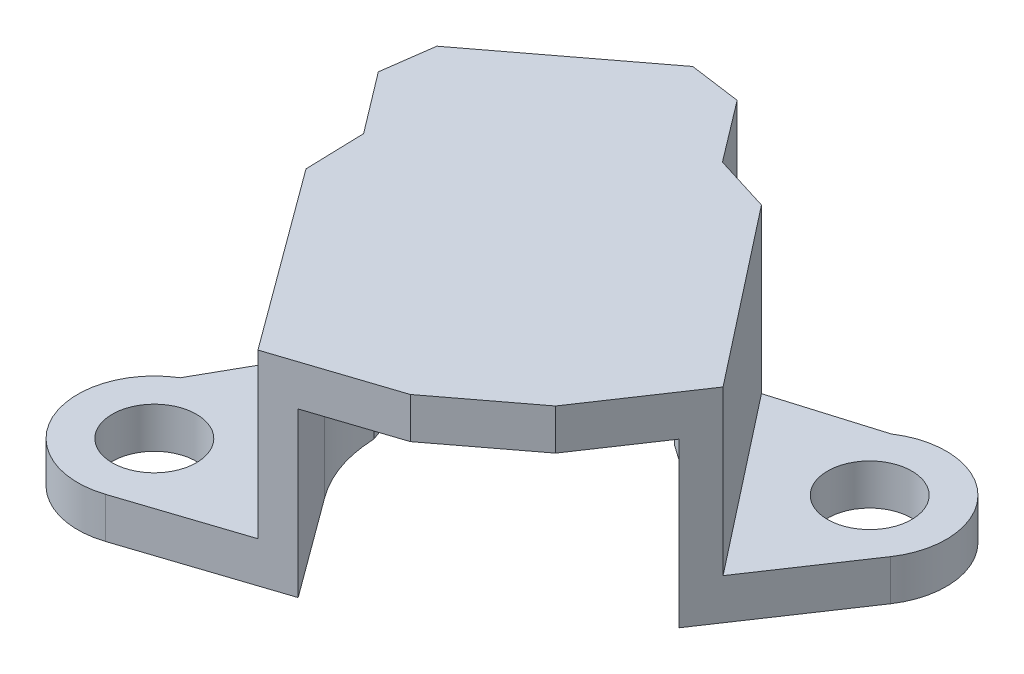
from build123d import *

# Parameters (mm, degrees)
SKETCH1_R             = 2.6162
BOSS_EXTRUDE1_DEPTH   = 2.54
BOSS_EXTRUDE1_2_DEPTH = 2.54
BOSS_EXTRUDE2_DEPTH   = 12.7
BOSS_EXTRUDE3_DEPTH   = 12.7
CUT_EXTRUDE1_DEPTH    = 10.16
BOSS_EXTRUDE5_DEPTH   = 12.7
CUT_EXTRUDE2_DEPTH    = 10.16


with BuildPart() as part:
    # Sketch1 → Boss-Extrude1 (new body)
    with BuildSketch(Plane(origin=(0, 0, 0), x_dir=(1, 0, 0), z_dir=(0, 1, 0))):
        with BuildLine():
            Line((-10.149829081, -0.78559745), (-12.970179614, -5.786096043))
            ThreePointArc((-12.970179614, -5.786096043), (-14.833663899, -11.850889023), (-9.017306722, -14.385504725))
            Line((-9.017306722, -14.385504725), (-1.886569513, -12.038188494))
            Line((-1.886569513, -12.038188494), (-10.149829081, -0.78559745))
        make_face()
        with Locations((-10.506432822, -9.861799418)):
            Circle(SKETCH1_R, mode=Mode.SUBTRACT)
    extrude(amount=BOSS_EXTRUDE1_DEPTH)



with BuildPart() as body_2:
    # Sketch1 → Boss-Extrude1 2 (new body)
    with BuildSketch(Plane(origin=(0, 0, 0), x_dir=(1, 0, 0), z_dir=(0, 1, 0))):
        with BuildLine():
            Line((5.95620443, 11.428082994), (14.562195858, 0.435395631))
            Line((14.562195858, 0.435395631), (18.746273034, 6.66843701))
            ThreePointArc((18.746273034, 6.66843701), (18.171308738, 12.678699935), (12.165175551, 13.29531044))
            Line((12.165175551, 13.29531044), (5.95620443, 11.428082994))
        make_face()
        with Locations((14.792061634, 9.322795398)):
            Circle(SKETCH1_R, mode=Mode.SUBTRACT)
    extrude(amount=BOSS_EXTRUDE1_2_DEPTH)


with BuildPart() as part_1:
    add(part.part)

    add(body_2.part)  # Boss-Extrude2 merges body 2
    # Sketch1_5 → Boss-Extrude2 (add)
    with BuildSketch(Plane(origin=(0, 0, 0), x_dir=(1, 0, 0), z_dir=(0, 1, 0))):
        with BuildLine():
            Line((-10.256120569, 2.902434291), (-10.149829081, -0.78559745))
            Line((-10.149829081, -0.78559745), (-1.886569513, -12.038188494))
            Line((-1.886569513, -12.038188494), (-0.005832357, -11.419082121))
            Line((-0.005832357, -11.419082121), (-4.572272753, -5.200678127))
            ThreePointArc((-4.572272753, -5.200678127), (-5.731382948, -2.990882077), (-6.18409173, -0.536948544))
            Line((-6.18409173, -0.536948544), (-6.647421935, 0.770957563))
            Line((-6.647421935, 0.770957563), (-12.168687381, 8.289605816))
            Line((-12.168687381, 8.289605816), (-1.892547948, 15.835815142))
            Line((-1.892547948, 15.835815142), (3.512453439, 8.475490841))
            Line((3.512453439, 8.475490841), (4.646859497, 7.676481354))
            ThreePointArc((4.646859497, 7.676481354), (6.992594353, 6.504605156), (8.857901564, 4.661674107))
            Line((8.857901564, 4.661674107), (13.456324189, -1.212027104))
            Line((13.456324189, -1.212027104), (14.562195858, 0.435395631))
            Line((14.562195858, 0.435395631), (5.95620443, 11.428082994))
            Line((5.95620443, 11.428082994), (2.433604251, 12.525427051))
            Line((2.433604251, 12.525427051), (-0.436996693, 16.310853991))
            Line((-0.436996693, 16.310853991), (-3.639779121, 16.751054765))
            Line((-3.639779121, 16.751054765), (-12.686520738, 9.890643659))
            Line((-12.686520738, 9.890643659), (-13.126721512, 6.687861232))
            Line((-13.126721512, 6.687861232), (-10.256120569, 2.902434291))
        make_face()
    extrude(amount=BOSS_EXTRUDE2_DEPTH)

    # Sketch1_6 → Boss-Extrude3 (add)
    with BuildSketch(Plane(origin=(0, 0, 0), x_dir=(1, 0, 0), z_dir=(0, 1, 0))):
        with BuildLine():
            Line((-6.647421935, 0.770957563), (-6.18409173, -0.536948544))
            ThreePointArc((-6.18409173, -0.536948544), (7.176852085, -6.907826955), (4.646859497, 7.676481354))
            Line((4.646859497, 7.676481354), (3.512453439, 8.475490841))
            Line((3.512453439, 8.475490841), (-1.892547948, 15.835815142))
            Line((-1.892547948, 15.835815142), (-12.168687381, 8.289605816))
            Line((-12.168687381, 8.289605816), (-6.647421935, 0.770957563))
        make_face()
    extrude(amount=BOSS_EXTRUDE3_DEPTH)

    # Sketch1_8 → Cut-Extrude1 (cut)
    with BuildSketch(Plane(origin=(0, 0, 0), x_dir=(1, 0, 0), z_dir=(0, 1, 0))):
        with BuildLine():
            Line((-6.647421935, 0.770957563), (-6.18409173, -0.536948544))
            ThreePointArc((-6.18409173, -0.536948544), (7.176852085, -6.907826955), (4.646859497, 7.676481354))
            Line((4.646859497, 7.676481354), (3.512453439, 8.475490841))
            Line((3.512453439, 8.475490841), (-1.892547948, 15.835815142))
            Line((-1.892547948, 15.835815142), (-12.168687381, 8.289605816))
            Line((-12.168687381, 8.289605816), (-6.647421935, 0.770957563))
        make_face()
    extrude(amount=CUT_EXTRUDE1_DEPTH, mode=Mode.SUBTRACT)

    # Sketch1_9 → Boss-Extrude5 (add)
    with BuildSketch(Plane(origin=(0, 0, 0), x_dir=(1, 0, 0), z_dir=(0, 1, 0))):
        with BuildLine():
            Line((-4.572272753, -5.200678127), (-0.005832357, -11.419082121))
            Line((-0.005832357, -11.419082121), (5.244167697, -9.690872263))
            Line((5.244167697, -9.690872263), (10.378118681, -5.797645747))
            Line((10.378118681, -5.797645747), (13.456324189, -1.212027104))
            Line((13.456324189, -1.212027104), (8.857901564, 4.661674107))
            ThreePointArc((8.857901564, 4.661674107), (7.073990523, -6.984589168), (-4.572272753, -5.200678127))
        make_face()
    extrude(amount=BOSS_EXTRUDE5_DEPTH)

    # Sketch1_11 → Cut-Extrude2 (cut)
    with BuildSketch(Plane(origin=(0, 0, 0), x_dir=(1, 0, 0), z_dir=(0, 1, 0))):
        with BuildLine():
            Line((-4.572272753, -5.200678127), (-0.005832357, -11.419082121))
            Line((-0.005832357, -11.419082121), (5.244167697, -9.690872263))
            Line((5.244167697, -9.690872263), (10.378118681, -5.797645747))
            Line((10.378118681, -5.797645747), (13.456324189, -1.212027104))
            Line((13.456324189, -1.212027104), (8.857901564, 4.661674107))
            ThreePointArc((8.857901564, 4.661674107), (7.073990523, -6.984589168), (-4.572272753, -5.200678127))
        make_face()
    extrude(amount=CUT_EXTRUDE2_DEPTH, mode=Mode.SUBTRACT)


solid = part_1.part
